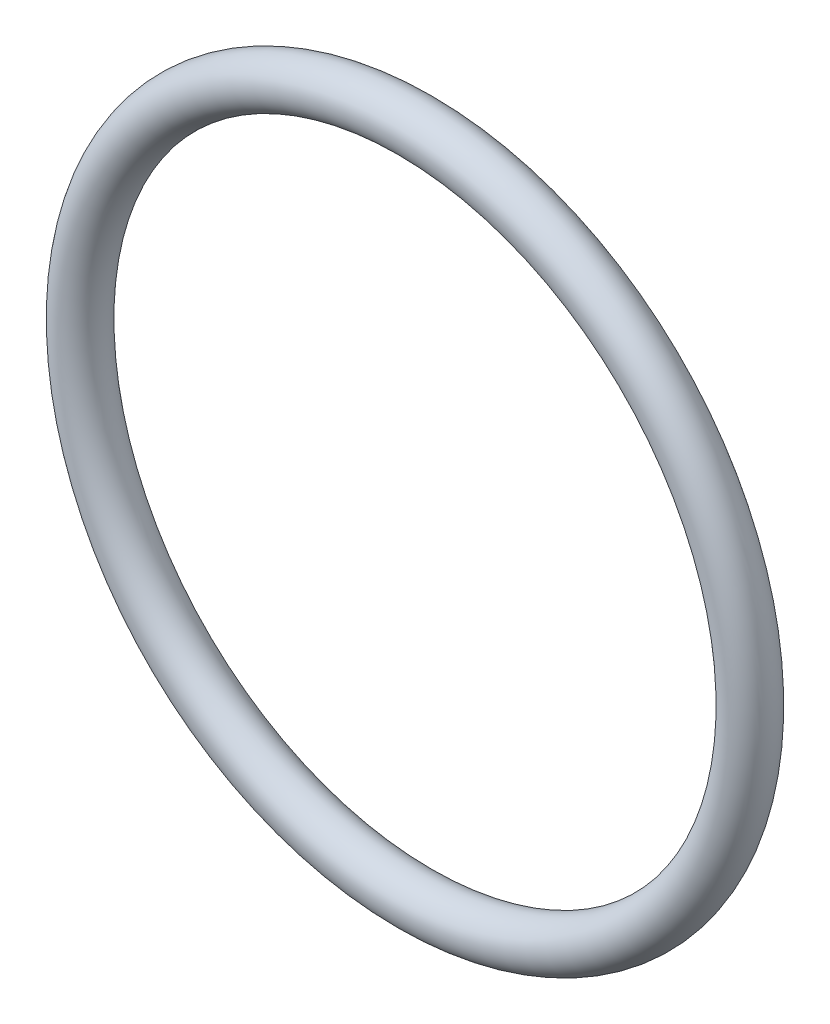
from build123d import *

# Parameters (mm, degrees)
ESQUISSE3_R = 2


with BuildPart() as part:
    # Balayage5: sweep along a path in Esquisse1
    with BuildLine(Plane.XY) as balayage5_path:
        CenterArc((0, 0), 28, 0, 360)
    # Esquisse3 → Balayage5 (sweep)
    with BuildSketch(Plane(origin=(0, 0, 0), x_dir=(0, 0, -1), z_dir=(1, 0, 0))):
        with Locations((0, 28)):
            Circle(ESQUISSE3_R)
    sweep(path=balayage5_path.line)


solid = part.part
